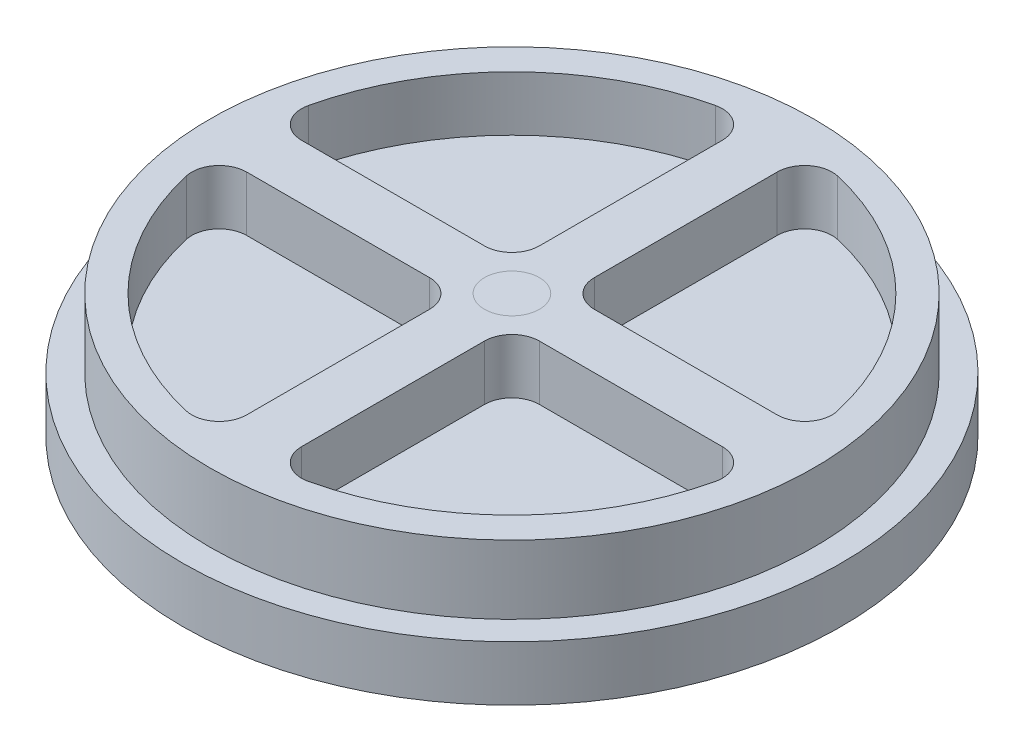
from build123d import *

# Parameters (mm, degrees)
SKETCH1_R           = 304.8
BOSS_EXTRUDE1_DEPTH = 50.8
SKETCH1_6_R         = 25.4
BOSS_EXTRUDE6_DEPTH = 63.5
SKETCH1_5_R         = 25.4
BOSS_EXTRUDE4_DEPTH = 50.8
SKETCH5_R           = 279.4
SKETCH5_R_2         = 25.4
BOSS_EXTRUDE5_DEPTH = 12.7
SKETCH6_R           = 279.4
SKETCH6_R_2         = 25.4
BOSS_EXTRUDE7_DEPTH = 50.8


with BuildPart() as part:
    # Sketch1 → Boss-Extrude1 (new body)
    with BuildSketch(Plane(origin=(0, 0, 0), x_dir=(1, 0, 0), z_dir=(0, 1, 0))):
        Circle(SKETCH1_R)
    extrude(amount=-BOSS_EXTRUDE1_DEPTH)

    # Sketch1_6 → Boss-Extrude6 (add)
    with BuildSketch(Plane(origin=(0, 0, 0), x_dir=(1, 0, 0), z_dir=(0, 1, 0))):
        Circle(SKETCH1_6_R)
    extrude(amount=BOSS_EXTRUDE6_DEPTH)

    # Sketch1_5 → Boss-Extrude4 (add)
    with BuildSketch(Plane(origin=(0, 0, 0), x_dir=(1, 0, 0), z_dir=(0, 1, 0))):
        Circle(SKETCH1_5_R)
    extrude(amount=BOSS_EXTRUDE4_DEPTH)


with BuildPart() as body_2:
    # Sketch5 → Boss-Extrude5 (new body)
    with BuildSketch(Plane(origin=(0, 0, 0), x_dir=(1, 0, 0), z_dir=(0, 1, 0))):
        Circle(SKETCH5_R)
        Circle(SKETCH5_R_2, mode=Mode.SUBTRACT)
    extrude(amount=BOSS_EXTRUDE5_DEPTH)


with BuildPart() as body_3:
    # Sketch6 → Boss-Extrude7 (new body)
    with BuildSketch(Plane(origin=(0, 12.7, 0), x_dir=(1, 0, 0), z_dir=(0, 1, 0))):
        Circle(SKETCH6_R)
        with BuildLine():
            Line((-25.4, -50.8), (-25.4, -219.912108973))
            ThreePointArc((-25.4, -219.912108973), (-34.98938499, -239.791355765), (-56.516886063, -244.660385959))
            ThreePointArc((-56.516886063, -244.660385959), (-177.556840009, -177.556840009), (-244.660385959, -56.516886063))
            ThreePointArc((-244.660385959, -56.516886063), (-239.791355765, -34.98938499), (-219.912108973, -25.4))
            Line((-219.912108973, -25.4), (-50.8, -25.4))
            ThreePointArc((-50.8, -25.4), (-32.839487758, -32.839487758), (-25.4, -50.8))
        make_face(mode=Mode.SUBTRACT)
        with BuildLine():
            Line((50.8, -25.4), (219.912108973, -25.4))
            ThreePointArc((219.912108973, -25.4), (239.791355765, -34.98938499), (244.660385959, -56.516886063))
            ThreePointArc((244.660385959, -56.516886063), (177.556840009, -177.556840009), (56.516886063, -244.660385959))
            ThreePointArc((56.516886063, -244.660385959), (34.98938499, -239.791355765), (25.4, -219.912108973))
            Line((25.4, -219.912108973), (25.4, -50.8))
            ThreePointArc((25.4, -50.8), (32.839487758, -32.839487758), (50.8, -25.4))
        make_face(mode=Mode.SUBTRACT)
        with BuildLine():
            Line((-50.8, 25.4), (-219.912108973, 25.4))
            ThreePointArc((-219.912108973, 25.4), (-239.791355765, 34.98938499), (-244.660385959, 56.516886063))
            ThreePointArc((-244.660385959, 56.516886063), (-177.556840009, 177.556840009), (-56.516886063, 244.660385959))
            ThreePointArc((-56.516886063, 244.660385959), (-34.98938499, 239.791355765), (-25.4, 219.912108973))
            Line((-25.4, 219.912108973), (-25.4, 50.8))
            ThreePointArc((-25.4, 50.8), (-32.839487758, 32.839487758), (-50.8, 25.4))
        make_face(mode=Mode.SUBTRACT)
        Circle(SKETCH6_R_2, mode=Mode.SUBTRACT)
        with BuildLine():
            Line((25.4, 50.8), (25.4, 219.912108973))
            ThreePointArc((25.4, 219.912108973), (34.98938499, 239.791355765), (56.516886063, 244.660385959))
            ThreePointArc((56.516886063, 244.660385959), (177.556840009, 177.556840009), (244.660385959, 56.516886063))
            ThreePointArc((244.660385959, 56.516886063), (239.791355765, 34.98938499), (219.912108973, 25.4))
            Line((219.912108973, 25.4), (50.8, 25.4))
            ThreePointArc((50.8, 25.4), (32.839487758, 32.839487758), (25.4, 50.8))
        make_face(mode=Mode.SUBTRACT)
    extrude(amount=BOSS_EXTRUDE7_DEPTH)

    # Combine1: union body 2
    add(body_2.part)


solid = Compound([part.part, body_3.part])
